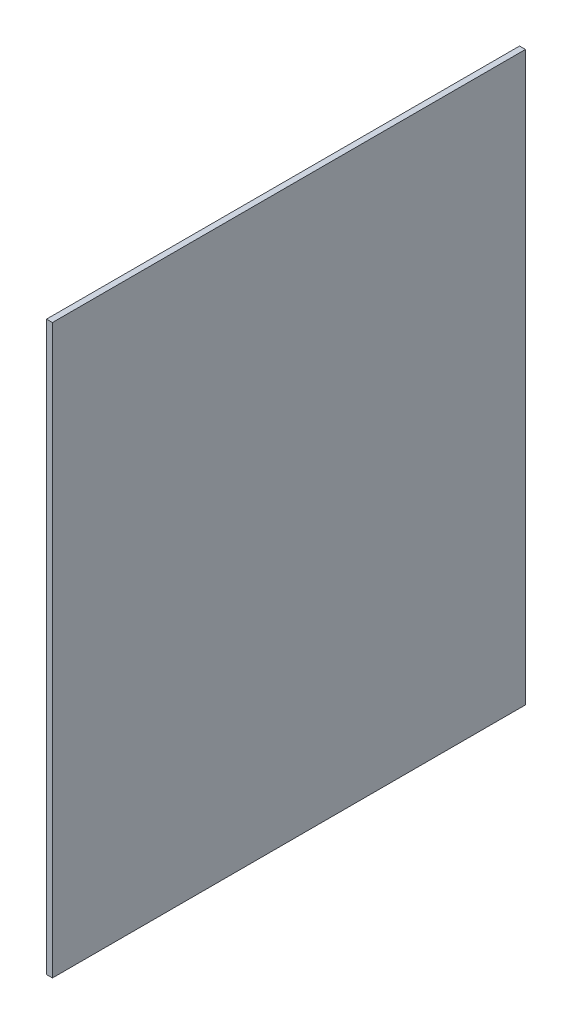
from build123d import *

# Parameters (mm, degrees)
SKETCH1_W           = 508
SKETCH1_H           = 609.6
BOSS_EXTRUDE1_DEPTH = 6.35


with BuildPart() as part:
    # Sketch1 → Boss-Extrude1 (new body)
    with BuildSketch(Plane(origin=(0, 0, 0), x_dir=(0, 0, -1), z_dir=(1, 0, 0))):
        with Locations((254, -304.8)):
            Rectangle(SKETCH1_W, SKETCH1_H)
    extrude(amount=BOSS_EXTRUDE1_DEPTH)


solid = part.part
